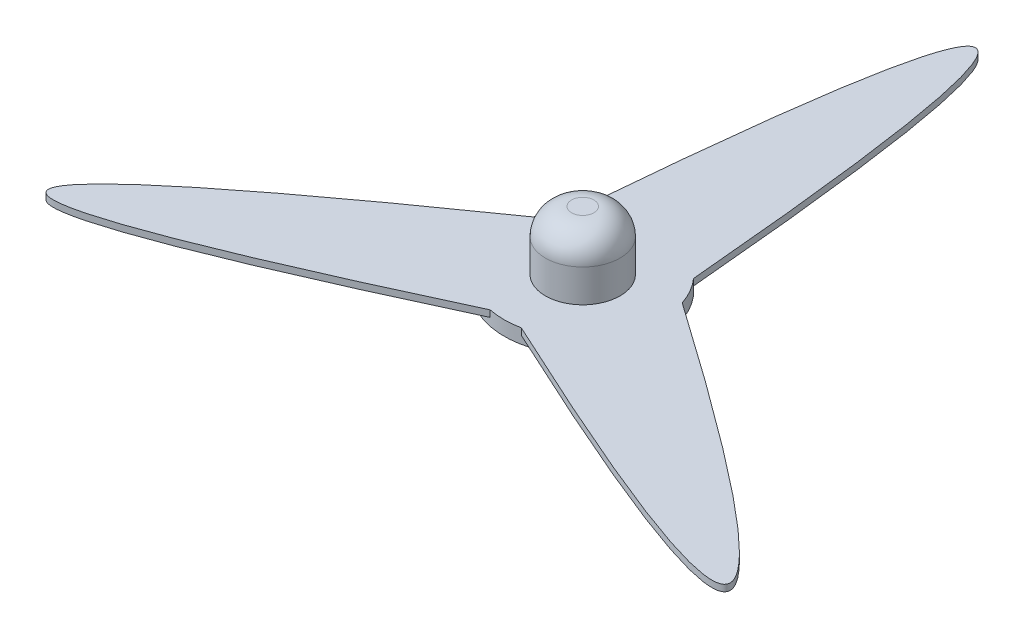
from build123d import *

# Parameters (mm, degrees)
BOSS_EXTRUDE1_DEPTH = 5
SKETCH2_R           = 28.5
BOSS_EXTRUDE2_DEPTH = 45
FILLET1_R           = 20
SKETCH3_R           = 60
BOSS_EXTRUDE3_DEPTH = 6
SKETCH4_R           = 24
CUT_EXTRUDE1_DEPTH  = 36


with BuildPart() as part:
    # Sketch1 → Boss-Extrude1 (new body)
    with BuildSketch(Plane(origin=(0, 0, 0), x_dir=(1, 0, 0), z_dir=(0, 1, 0))):
        with BuildLine():
            ThreePointArc((-45, 39.686269666), (-51.961524227, 30), (-56.869317712, 19.128008337))
            add(Edge.make_bspline(
                [(-11.869317712, -58.814278003), (-485.245924558, -280.156865167), (-56.869317712, 19.128008337)],
                knots=[0, 0, 0, 1, 1, 1], degree=2))
            ThreePointArc((-11.869317712, -58.814278003), (0, -60), (11.869317712, -58.814278003))
            add(Edge.make_bspline(
                [(56.869317712, 19.128008337), (485.245924558, -280.156865167), (11.869317712, -58.814278003)],
                knots=[0, 0, 0, 1, 1, 1], degree=2))
            ThreePointArc((56.869317712, 19.128008337), (51.961524227, 30), (45, 39.686269666))
            add(Edge.make_bspline(
                [(-45, 39.686269666), (0, 560.313730334), (45, 39.686269666)],
                knots=[0, 0, 0, 1, 1, 1], degree=2))
        make_face()
    extrude(amount=BOSS_EXTRUDE1_DEPTH)

    # Sketch2 → Boss-Extrude2 (add)
    with BuildSketch(Plane(origin=(0, 5, 0), x_dir=(1, 0, 0), z_dir=(0, 1, 0))):
        Circle(SKETCH2_R)
    extrude(amount=BOSS_EXTRUDE2_DEPTH)

    # Fillet1
    fillet1_edges = [part.edges().sort_by_distance(p)[0] for p in [
        (-28.5, 50, 0),
    ]]
    fillet(fillet1_edges, radius=FILLET1_R)

    # Sketch3 → Boss-Extrude3 (add)
    with BuildSketch(Plane.XZ):
        Circle(SKETCH3_R)
    extrude(amount=BOSS_EXTRUDE3_DEPTH)

    # Sketch4 → Cut-Extrude1 (cut)
    with BuildSketch(Plane.XZ.offset(6)):
        Circle(SKETCH4_R)
    extrude(amount=-CUT_EXTRUDE1_DEPTH, mode=Mode.SUBTRACT)


solid = part.part
